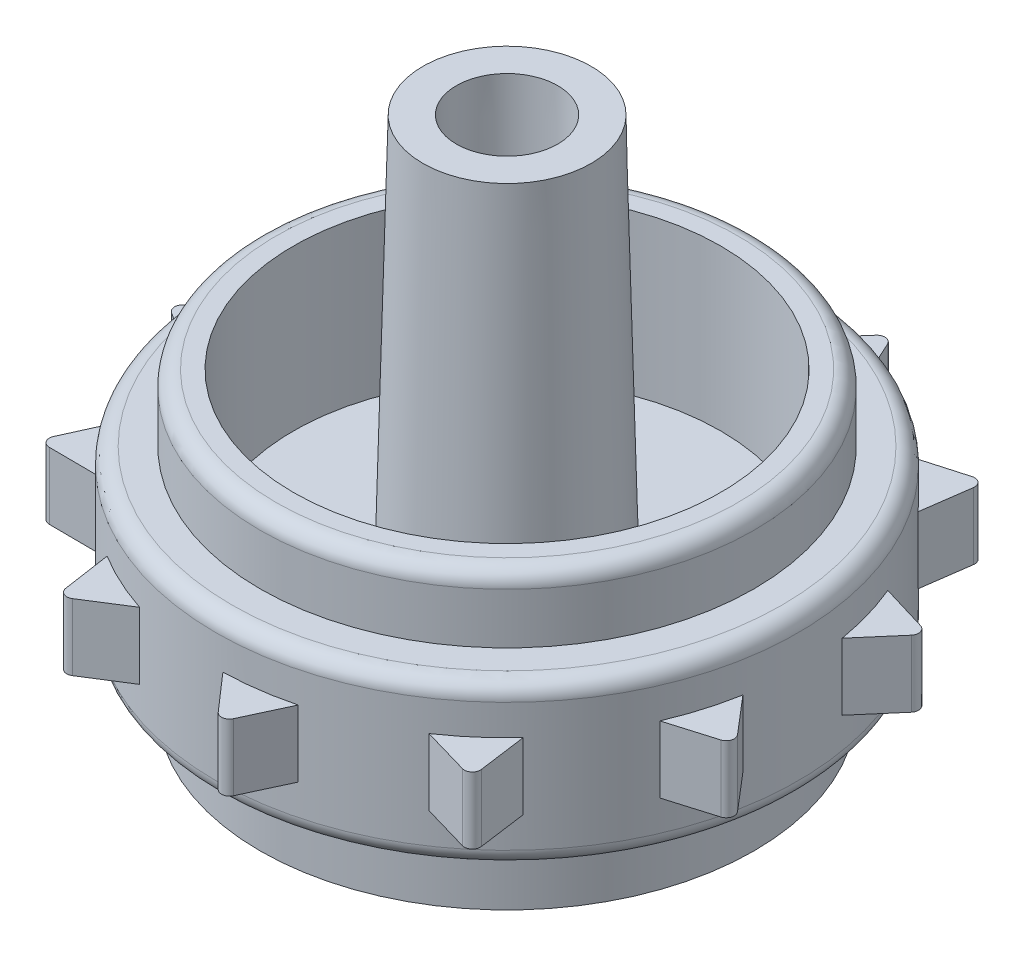
from build123d import *
from OCP.BRepFilletAPI import BRepFilletAPI_MakeFillet

# Parameters (mm, degrees)
SKETCH1_R           = 9.250000042
BOSS_EXTRUDE1_DEPTH = 2.5
SKETCH2_R           = 10.9
BOSS_EXTRUDE2_DEPTH = 6
SKETCH3_R           = 9.250000042
BOSS_EXTRUDE3_DEPTH = 2.5
SKETCH4_R           = 8
CUT_EXTRUDE1_DEPTH  = 3.5
CUT_EXTRUDE2_START  = -6
SKETCH5_R           = 8
CUT_EXTRUDE2_DEPTH  = 6
SKETCH6_R           = 3.15
BOSS_EXTRUDE4_DEPTH = 4.8
SKETCH7_R           = 3.5
SKETCH7_R_2         = 1.55
BOSS_EXTRUDE5_DEPTH = 14.25
BOSS_EXTRUDE5_DRAFT = 1.4
FILLET1_R1          = 0.6
FILLET1_R2          = 1
BOSS_EXTRUDE6_DEPTH = 2.5
FILLET2_R           = 0.3


with BuildPart() as part:
    # Sketch1 → Boss-Extrude1 (new body)
    with BuildSketch(Plane(origin=(0, 0, 0), x_dir=(1, 0, 0), z_dir=(0, 1, 0))):
        Circle(SKETCH1_R)
    extrude(amount=BOSS_EXTRUDE1_DEPTH)

    # Sketch2 → Boss-Extrude2 (add)
    with BuildSketch(Plane(origin=(0, 2.5, 0), x_dir=(1, 0, 0), z_dir=(0, 1, 0))):
        Circle(SKETCH2_R)
    extrude(amount=BOSS_EXTRUDE2_DEPTH)

    # Sketch3 → Boss-Extrude3 (add)
    with BuildSketch(Plane(origin=(0, 8.5, 0), x_dir=(1, 0, 0), z_dir=(0, 1, 0))):
        Circle(SKETCH3_R)
    extrude(amount=BOSS_EXTRUDE3_DEPTH)

    # Sketch4 → Cut-Extrude1 (cut)
    with BuildSketch(Plane.XZ):
        Circle(SKETCH4_R)
    extrude(amount=-CUT_EXTRUDE1_DEPTH, mode=Mode.SUBTRACT)

    # Sketch5 → Cut-Extrude2 (cut)
    with BuildSketch(Plane(origin=(0, 11, 0), x_dir=(1, 0, 0), z_dir=(0, 1, 0)).offset(CUT_EXTRUDE2_START)):
        Circle(SKETCH5_R)
    extrude(amount=CUT_EXTRUDE2_DEPTH, mode=Mode.SUBTRACT)

    # Sketch6 → Boss-Extrude4 (add)
    with BuildSketch(Plane.XZ.offset(-3.5)):
        Circle(SKETCH6_R)
    extrude(amount=BOSS_EXTRUDE4_DEPTH)


with BuildPart() as boss_extrude5_tool:
    # Sketch7 → Boss-Extrude5 (with draft: the straight prism first)
    with BuildSketch(Plane(origin=(0, 5, 0), x_dir=(1, 0, 0), z_dir=(0, 1, 0))):
        Circle(SKETCH7_R)
        Circle(SKETCH7_R_2, mode=Mode.SUBTRACT)
    extrude(amount=BOSS_EXTRUDE5_DEPTH)
    # Boss-Extrude5: the draft: its side faces are tilted about the plane it starts from
    boss_extrude5_sides = [boss_extrude5_tool.faces().sort_by_distance(p)[0] for p in [
        (-3.5, 12.125, 0),
        (-1.55, 12.125, 0),
    ]]
    draft(boss_extrude5_sides, Plane(origin=(0, 5, 0), x_dir=(1, 0, 0), z_dir=(0, 1, 0)), BOSS_EXTRUDE5_DRAFT)


with BuildPart() as part_1:
    add(part.part)

    # Boss-Extrude5: add boss_extrude5_tool
    add(boss_extrude5_tool.part)

    # Fillet1: one fillet with a radius per group of edges: ONE call of the kernel's fillet builder (fillet() takes one radius for all edges)
    fillet1_edges_1 = [part_1.edges().sort_by_distance(p)[0] for p in [
        (-9.250000042, 11, 0),
        (-10.9, 8.5, 0),
        (-10.9, 2.5, 0),
        (-8, 0, 0),
    ]]
    fillet1_edges_2 = [part_1.edges().sort_by_distance(p)[0] for p in [
        (-3.15, -1.3, 0),
    ]]
    fillet1 = BRepFilletAPI_MakeFillet(part_1.part.solid().wrapped)
    for e in fillet1_edges_1:
        fillet1.Add(FILLET1_R1, e.wrapped)
    for e in fillet1_edges_2:
        fillet1.Add(FILLET1_R2, e.wrapped)
    add(Compound.cast(fillet1.Shape()), mode=Mode.REPLACE)

    # Sketch8 → Boss-Extrude6 (add)
    with BuildSketch(Plane(origin=(0, 4.25, 0), x_dir=(1, 0, 0), z_dir=(0, 1, 0))):
        Polygon((-12.749903868, 0.049485427), (-10.833686569, -1.200514613), (-10.822261202, 1.299485467), align=None)
        Polygon((-10.69914783, 6.93474824), (-9.762924301, 4.847196003), (-8.401710584, 6.944152883), align=None)
        Polygon((-5.251487953, 11.618277485), (-5.592502549, 9.355956137), (-3.313676219, 10.384100824), align=None)
        Polygon((1.863482244, 12.61308572), (0.353499247, 10.894266303), (2.826426932, 10.527170123), align=None)
        Polygon((8.386809995, 9.603328358), (6.18726753, 8.973723893), (8.069159502, 7.32793729), align=None)
        Polygon((12.247384832, 3.544582096), (10.056622089, 4.204087553), (10.749990945, 1.802136144), align=None)
        Polygon((12.21950152, -3.639543936), (10.733070192, -1.900316881), (10.017776218, -4.295830494), align=None)
        Polygon((8.312012814, -9.668140485), (8.001844345, -7.401384132), (6.104988325, -9.029901304), align=None)
        Polygon((1.76551877, -12.627170741), (2.730089457, -10.552564217), (0.253909774, -10.897042251), align=None)
        Polygon((-5.341515009, -11.577163507), (-3.408449544, -10.353379724), (-5.677783336, -9.304449279), align=None)
        Polygon((-10.752655514, -6.851488659), (-8.464829898, -6.867070322), (-9.806820355, -4.757759403), align=None)
    extrude(amount=BOSS_EXTRUDE6_DEPTH)

    # Fillet2
    fillet2_edges = [part_1.edges().sort_by_distance(p)[0] for p in [
        (-12.749903868, 5.5, -0.049485427),
        (-10.69914783, 5.5, -6.93474824),
        (-5.251487953, 5.5, -11.618277485),
        (1.863482244, 5.5, -12.61308572),
        (8.386809995, 5.5, -9.603328358),
        (12.247384832, 5.5, -3.544582096),
        (12.21950152, 5.5, 3.639543936),
        (-10.752655514, 5.5, 6.851488659),
        (-5.341515009, 5.5, 11.577163507),
        (1.76551877, 5.5, 12.627170741),
        (8.312012814, 5.5, 9.668140485),
    ]]
    fillet(fillet2_edges, radius=FILLET2_R)


solid = part_1.part
